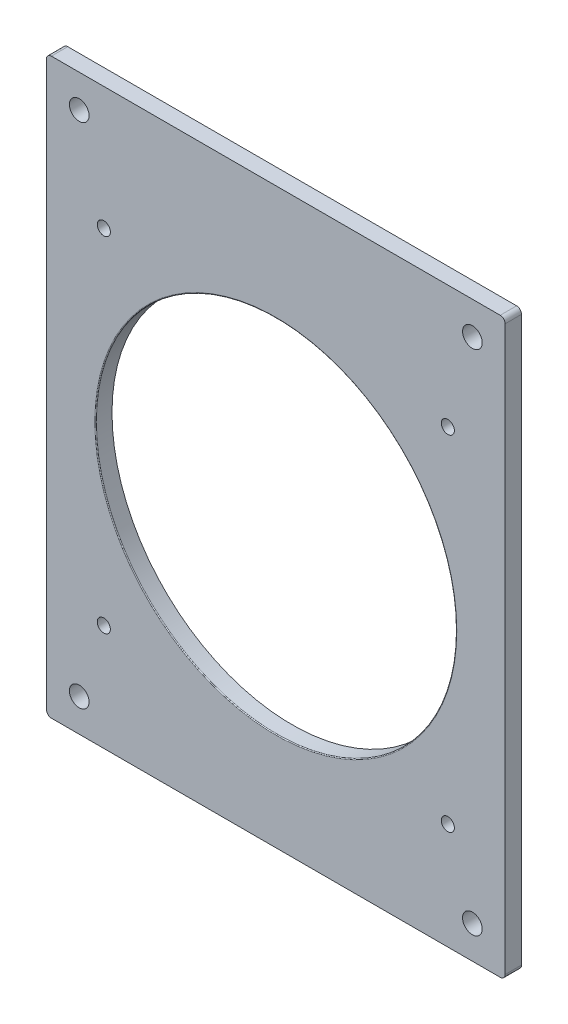
from build123d import *

# Parameters (mm, degrees)
BOSS_EXTRU_1_DEPTH      = 5
ESQUISSE4_R             = 3
ENL_V_MAT_EXTRU_3_DEPTH = 10
ESQUISSE5_R             = 2
ESQUISSE5_R_2           = 55
ENL_V_MAT_EXTRU_4_DEPTH = 10
CONG_1_R                = 0.25


with BuildPart() as part:
    # Esquisse1 → Boss.-Extru.1 (new body)
    with BuildSketch(Plane.XY):
        with BuildLine():
            Line((-68, 87.5), (-68.5, 87.5))
            ThreePointArc((-68.5, 87.5), (-69.560660172, 87.060660172), (-70, 86))
            Line((-70, 86), (-70, 75.5))
            Line((-70, 75.5), (-70, -85.5))
            Line((-70, -85.5), (-70, -86))
            ThreePointArc((-70, -86), (-69.560660172, -87.060660172), (-68.5, -87.5))
            Line((-68.5, -87.5), (-68, -87.5))
            Line((-68, -87.5), (68, -87.5))
            Line((68, -87.5), (68.5, -87.5))
            ThreePointArc((68.5, -87.5), (69.560660172, -87.060660172), (70, -86))
            Line((70, -86), (70, -85.5))
            Line((70, -85.5), (70, 75.5))
            Line((70, 75.5), (70, 86))
            ThreePointArc((70, 86), (69.560660172, 87.060660172), (68.5, 87.5))
            Line((68.5, 87.5), (68, 87.5))
            Line((68, 87.5), (-68, 87.5))
        make_face()
    extrude(amount=BOSS_EXTRU_1_DEPTH)

    # Esquisse4 → Enlèv. mat.-Extru.3 (cut)
    with BuildSketch(Plane.XY.offset(5)):
        with Locations((-60, -77.5)):
            Circle(ESQUISSE4_R)
        with Locations((60, -77.5)):
            Circle(ESQUISSE4_R)
        with Locations((-60, 77.5)):
            Circle(ESQUISSE4_R)
        with Locations((60, 77.5)):
            Circle(ESQUISSE4_R)
    extrude(amount=-ENL_V_MAT_EXTRU_3_DEPTH, mode=Mode.SUBTRACT)

    # Esquisse5 → Enlèv. mat.-Extru.4 (cut)
    with BuildSketch(Plane(origin=(0, 0, 0), x_dir=(-1, 0, 0), z_dir=(0, 0, -1))):
        with Locations((-52.5, 50)):
            Circle(ESQUISSE5_R)
        with Locations((52.5, 50)):
            Circle(ESQUISSE5_R)
        with Locations((52.5, -55)):
            Circle(ESQUISSE5_R)
        with Locations((-52.5, -55)):
            Circle(ESQUISSE5_R)
        with Locations((0, -2.5)):
            Circle(ESQUISSE5_R_2)
    extrude(amount=-ENL_V_MAT_EXTRU_4_DEPTH, mode=Mode.SUBTRACT)

    # Congé1
    cong_1_edges = [part.edges().sort_by_distance(p)[0] for p in [
        (55, -2.5, 5),
    ]]
    fillet(cong_1_edges, radius=CONG_1_R)


solid = part.part
